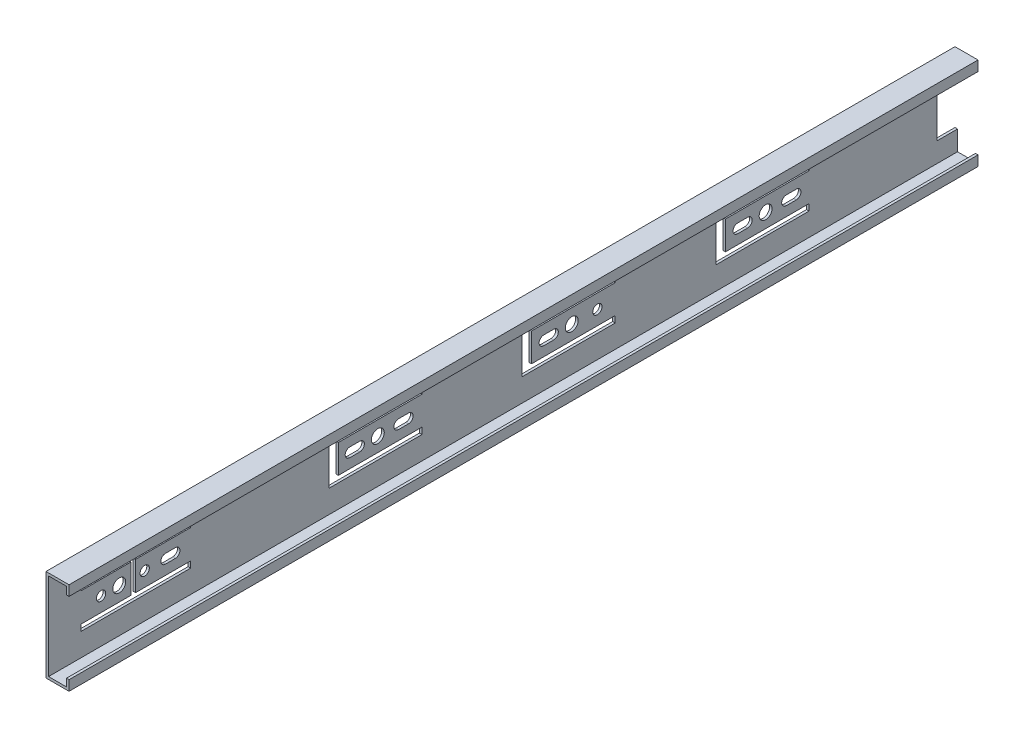
from build123d import *

# Parameters (mm, degrees)
SKETCH1_W                      = 450
SKETCH1_H                      = 45.7
BOSS_EXTRUDE1_DEPTH            = 11.4
CUT_EXTRUDE1_DEPTH             = 451
SKETCH3_W                      = 10.25
SKETCH3_H                      = 23.6
CUT_EXTRUDE2_DEPTH             = 12.4
CUT_EXTRUDE3_DEPTH             = 2.27
CUT_EXTRUDE4_DEPTH             = 2.27
CUT_EXTRUDE5_DEPTH             = 2.27
CUT_EXTRUDE6_DEPTH             = 2.27
CUT_EXTRUDE7_DEPTH             = 2.27
CUT_EXTRUDE8_DEPTH             = 2.27
CUT_EXTRUDE9_DEPTH             = 2.27
CUT_EXTRUDE10_DEPTH            = 2.27
CUT_EXTRUDE11_DEPTH            = 2.27
CUT_EXTRUDE12_DEPTH            = 12.4
F_6_4_6_4_DIAMETER_HOLE1_D     = 6.4
F_6_4_6_4_DIAMETER_HOLE1_DEPTH = 11.4
F_4_6_4_6_DIAMETER_HOLE1_D     = 4.6
F_4_6_4_6_DIAMETER_HOLE1_DEPTH = 11.4
SCALE1_SCALE                   = 0.25


with BuildPart() as part:
    # Sketch1 → Boss-Extrude1 (new body)
    with BuildSketch(Plane(origin=(5.7, 0, 0), x_dir=(0, 0, -1), z_dir=(1, 0, 0))):
        with Locations((-225, 0)):
            Rectangle(SKETCH1_W, SKETCH1_H)
    extrude(amount=-BOSS_EXTRUDE1_DEPTH)

    # Sketch2 → Cut-Extrude1 (cut, through all)
    with BuildSketch(Plane.XY.offset(450)):
        Polygon((5.7, 17.85), (4.43, 17.85), (4.43, 21.58), (-4.43, 21.58), (-4.43, -21.58), (4.43, -21.58), (4.43, -17.85), (5.7, -17.85), align=None)
    extrude(amount=-CUT_EXTRUDE1_DEPTH, mode=Mode.SUBTRACT)

    # Sketch3 → Cut-Extrude2 (cut, through all)
    with BuildSketch(Plane.ZY.offset(5.7)):
        with Locations((5.125, 0)):
            Rectangle(SKETCH3_W, SKETCH3_H)
    extrude(amount=-CUT_EXTRUDE2_DEPTH, mode=Mode.SUBTRACT)

    # Sketch4 → Cut-Extrude3 (cut, through all)
    with BuildSketch(Plane(origin=(-4.43, 0, 0), x_dir=(0, 0, -1), z_dir=(1, 0, 0))):
        Polygon((-169.5, -10.25), (-169.5, -7.05), (-210.9, -7.05), (-210.9, 7.05), (-169.5, 7.05), (-169.5, 10.25), (-215.5, 10.25), (-215.5, -10.25), align=None)
    extrude(amount=-CUT_EXTRUDE3_DEPTH, mode=Mode.SUBTRACT)

    # Sketch5 → Cut-Extrude4 (cut, through all)
    with BuildSketch(Plane(origin=(-4.43, 0, 0), x_dir=(0, 0, -1), z_dir=(1, 0, 0))):
        Polygon((-119.5, -10.25), (-73.5, -10.25), (-73.5, -7.05), (-114.9, -7.05), (-114.9, 7.05), (-73.5, 7.05), (-73.5, 10.25), (-119.5, 10.25), align=None)
    extrude(amount=-CUT_EXTRUDE4_DEPTH, mode=Mode.SUBTRACT)

    # Sketch6 → Cut-Extrude5 (cut, through all)
    with BuildSketch(Plane(origin=(-4.43, 0, 0), x_dir=(0, 0, -1), z_dir=(1, 0, 0))):
        Polygon((-265.15, 7.05), (-265.15, 10.25), (-311.15, 10.25), (-311.15, -10.25), (-265.15, -10.25), (-265.15, -7.05), (-306.55, -7.05), (-306.55, 7.05), align=None)
    extrude(amount=-CUT_EXTRUDE5_DEPTH, mode=Mode.SUBTRACT)

    # Sketch7 → Cut-Extrude6 (cut, through all)
    with BuildSketch(Plane(origin=(-4.43, 0, 0), x_dir=(0, 0, -1), z_dir=(1, 0, 0))):
        with BuildLine():
            Line((-79.85, 2.3), (-84.75, 2.3))
            ThreePointArc((-84.75, 2.3), (-87.05, 0), (-84.75, -2.3))
            Line((-84.75, -2.3), (-79.85, -2.3))
            ThreePointArc((-79.85, -2.3), (-77.55, 0), (-79.85, 2.3))
        make_face()
    extrude(amount=-CUT_EXTRUDE6_DEPTH, mode=Mode.SUBTRACT)

    # Sketch8 → Cut-Extrude7 (cut, through all)
    with BuildSketch(Plane(origin=(-4.43, 0, 0), x_dir=(0, 0, -1), z_dir=(1, 0, 0))):
        with BuildLine():
            Line((-108.85, -2.3), (-103.95, -2.3))
            ThreePointArc((-103.95, -2.3), (-101.65, 0), (-103.95, 2.3))
            Line((-103.95, 2.3), (-108.85, 2.3))
            ThreePointArc((-108.85, 2.3), (-111.15, 0), (-108.85, -2.3))
        make_face()
    extrude(amount=-CUT_EXTRUDE7_DEPTH, mode=Mode.SUBTRACT)

    # Sketch9 → Cut-Extrude8 (cut, through all)
    with BuildSketch(Plane(origin=(-4.43, 0, 0), x_dir=(0, 0, -1), z_dir=(1, 0, 0))):
        with BuildLine():
            Line((-387.25, 2.3), (-392.15, 2.3))
            ThreePointArc((-392.15, 2.3), (-394.45, 0), (-392.15, -2.3))
            Line((-392.15, -2.3), (-387.25, -2.3))
            ThreePointArc((-387.25, -2.3), (-384.95, 0), (-387.25, 2.3))
        make_face()
    extrude(amount=-CUT_EXTRUDE8_DEPTH, mode=Mode.SUBTRACT)

    # Sketch10 → Cut-Extrude9 (cut, through all)
    with BuildSketch(Plane(origin=(-4.43, 0, 0), x_dir=(0, 0, -1), z_dir=(1, 0, 0))):
        with BuildLine():
            Line((-199.95, 2.3), (-204.85, 2.3))
            ThreePointArc((-204.85, 2.3), (-207.15, 0), (-204.85, -2.3))
            Line((-204.85, -2.3), (-199.95, -2.3))
            ThreePointArc((-199.95, -2.3), (-197.65, 0), (-199.95, 2.3))
        make_face()
    extrude(amount=-CUT_EXTRUDE9_DEPTH, mode=Mode.SUBTRACT)

    # Sketch11 → Cut-Extrude10 (cut, through all)
    with BuildSketch(Plane(origin=(-4.43, 0, 0), x_dir=(0, 0, -1), z_dir=(1, 0, 0))):
        with BuildLine():
            Line((-295.95, 2.3), (-300.85, 2.3))
            ThreePointArc((-300.85, 2.3), (-303.15, 0), (-300.85, -2.3))
            Line((-300.85, -2.3), (-295.95, -2.3))
            ThreePointArc((-295.95, -2.3), (-293.65, 0), (-295.95, 2.3))
        make_face()
    extrude(amount=-CUT_EXTRUDE10_DEPTH, mode=Mode.SUBTRACT)

    # Sketch12 → Cut-Extrude11 (cut, through all)
    with BuildSketch(Plane(origin=(-4.43, 0, 0), x_dir=(0, 0, -1), z_dir=(1, 0, 0))):
        with BuildLine():
            Line((-271.85, 2.3), (-276.75, 2.3))
            ThreePointArc((-276.75, 2.3), (-279.05, 0), (-276.75, -2.3))
            Line((-276.75, -2.3), (-271.85, -2.3))
            ThreePointArc((-271.85, -2.3), (-269.55, 0), (-271.85, 2.3))
        make_face()
    extrude(amount=-CUT_EXTRUDE11_DEPTH, mode=Mode.SUBTRACT)

    # Sketch13 → Cut-Extrude12 (cut, through all)
    with BuildSketch(Plane.ZY.offset(5.7)):
        Polygon((434, -7.15), (409.2, -7.15), (409.2, 7.15), (434, 7.15), (434, 10.25), (379.65, 10.25), (379.65, 7.15), (406.9, 7.15), (406.9, -7.15), (379.65, -7.15), (379.65, -10.25), (434, -10.25), align=None)
    extrude(amount=-CUT_EXTRUDE12_DEPTH, mode=Mode.SUBTRACT)

    # Ø6.4 (6.4) Diameter Hole1
    with Locations(Plane.ZY.offset(5.7)):
        with Locations((415, 0), (287, 0), (191, 0), (95, 0)):
            Hole(F_6_4_6_4_DIAMETER_HOLE1_D / 2, depth=F_6_4_6_4_DIAMETER_HOLE1_DEPTH)

    # Ø4.6 (4.6) Diameter Hole1
    with Locations(Plane.ZY.offset(5.7)):
        with Locations((424, 0), (402.4, 0), (178.3, 0)):
            Hole(F_4_6_4_6_DIAMETER_HOLE1_D / 2, depth=F_4_6_4_6_DIAMETER_HOLE1_DEPTH)


with BuildPart() as part_1:
    # Scale1: scaled about (-2.285927212, 0, 225.277222982)
    add(part.part.scale(SCALE1_SCALE).moved(Location((-1.714445409, 0, 168.957917237))))


solid = part_1.part
